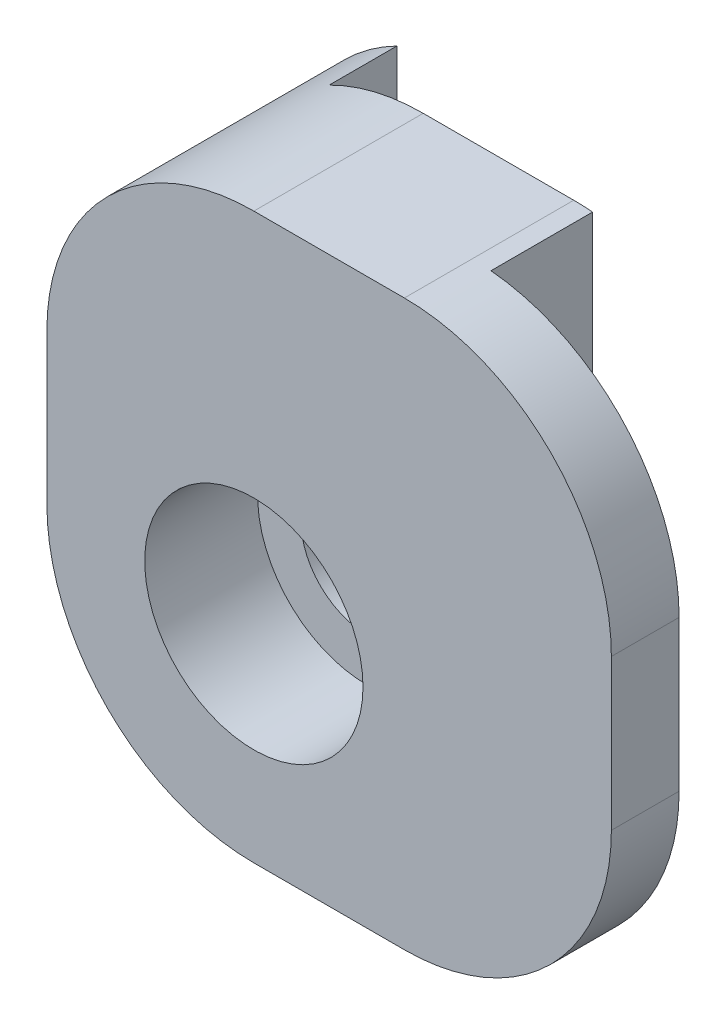
from build123d import *

# Parameters (mm, degrees)
ESBO_O3_W                = 7
ESBO_O3_H                = 12
ESBO_O3_R                = 1.75
RESSALTO_EXTRUS_O2_DEPTH = 2.7
ESBO_O4_W                = 7
ESBO_O4_H                = 12
ESBO_O4_R                = 1.75
RESSALTO_EXTRUS_O3_DEPTH = 2.1
ESBO_O5_W                = 2.1
ESBO_O5_H                = 12
RESSALTO_EXTRUS_O4_DEPTH = 5
RESSALTO_EXTRUS_O5_DEPTH = 3
ESBO_O7_W                = 4.8
ESBO_O7_H                = 15
RESSALTO_EXTRUS_O6_DEPTH = 3
ESBO_O8_R                = 2.9
CORTE_EXTRUS_O1_DEPTH    = 3
FILETE1_R                = 5.5
RESSALTO_EXTRUS_O7_DEPTH = 1.5
CORTE_EXTRUS_O4_DEPTH    = 6.3
CORTE_EXTRUS_O5_DEPTH    = 6.3
RESSALTO_EXTRUS_O8_DEPTH = 0.3
CORTE_EXTRUS_O6_DEPTH    = 0.3
ESBO_O17_R               = 2.9
CORTE_EXTRUS_O7_DEPTH    = 0.3


with BuildPart() as part:
    # Esboço3 → Ressalto-extrusão2 (new body)
    with BuildSketch(Plane.XY):
        with Locations((-3.5, 6)):
            Rectangle(ESBO_O3_W, ESBO_O3_H)
        with Locations((-2.5, 2.5)):
            Circle(ESBO_O3_R, mode=Mode.SUBTRACT)
    extrude(amount=RESSALTO_EXTRUS_O2_DEPTH)

    # Esboço4 → Ressalto-extrusão3 (add)
    with BuildSketch(Plane.XY.offset(2.7)):
        with Locations((-3.5, 6)):
            Rectangle(ESBO_O4_W, ESBO_O4_H)
        with Locations((-2.5, 2.5)):
            Circle(ESBO_O4_R, mode=Mode.SUBTRACT)
    extrude(amount=RESSALTO_EXTRUS_O3_DEPTH)

    # Esboço5 → Ressalto-extrusão4 (add)
    with BuildSketch(Plane.ZY.offset(7)):
        with Locations((3.75, 6)):
            Rectangle(ESBO_O5_W, ESBO_O5_H)
    extrude(amount=RESSALTO_EXTRUS_O4_DEPTH)

    # Esboço6 → Ressalto-extrusão5 (add)
    with BuildSketch(Plane.XZ):
        Polygon((-7, 0), (0, 0), (0, 4.8), (-12, 4.8), (-12, 2.7), (-7, 2.7), align=None)
    extrude(amount=RESSALTO_EXTRUS_O5_DEPTH)

    # Esboço7 → Ressalto-extrusão6 (add)
    with BuildSketch(Plane(origin=(0, 0, 0), x_dir=(0, 0, -1), z_dir=(1, 0, 0))):
        with Locations((-2.4, 4.5)):
            Rectangle(ESBO_O7_W, ESBO_O7_H)
    extrude(amount=RESSALTO_EXTRUS_O6_DEPTH)

    # Esboço8 → Corte-extrusão1 (cut)
    with BuildSketch(Plane.XY.offset(4.8)):
        with Locations((-2.5, 2.5)):
            Circle(ESBO_O8_R)
    extrude(amount=-CORTE_EXTRUS_O1_DEPTH, mode=Mode.SUBTRACT)

    # Filete1
    filete1_edges = [part.edges().sort_by_distance(p)[0] for p in [
        (3, -3, 2.4),
    ]]
    fillet(filete1_edges, radius=FILETE1_R)

    # Esboço10 → Ressalto-extrusão7 (add)
    with BuildSketch(Plane(origin=(0, 0, 0), x_dir=(-1, 0, 0), z_dir=(0, 0, -1))):
        with BuildLine():
            Line((7, 0), (0, 0))
            Line((0, 0), (0, 12))
            Line((0, 12), (-3, 12))
            Line((-3, 12), (-3, 2.5))
            ThreePointArc((-3, 2.5), (-1.389087297, -1.389087297), (2.5, -3))
            Line((2.5, -3), (7, -3))
            Line((7, -3), (7, 0))
        make_face()
    extrude(amount=RESSALTO_EXTRUS_O7_DEPTH)

    # Esboço14 → Corte-extrusão4 (cut)
    with BuildSketch(Plane.XY.offset(4.8)):
        with BuildLine():
            Line((-12, 12), (-12, 6.5))
            ThreePointArc((-12, 6.5), (-10.389087297, 10.389087297), (-6.5, 12))
            Line((-6.5, 12), (-12, 12))
        make_face()
        with BuildLine():
            ThreePointArc((-2.5, 12), (1.389087297, 10.389087297), (3, 6.5))
            Line((3, 6.5), (3, 12))
            Line((3, 12), (-2.5, 12))
        make_face()
    extrude(amount=-CORTE_EXTRUS_O4_DEPTH, mode=Mode.SUBTRACT)

    # Esboço13 → Corte-extrusão5 (cut)
    with BuildSketch(Plane.XY.offset(4.8)):
        with BuildLine():
            Line((-12, -3), (-6.5, -3))
            ThreePointArc((-6.5, -3), (-10.389087297, -1.389087297), (-12, 2.5))
            Line((-12, 2.5), (-12, -3))
        make_face()
    extrude(amount=-CORTE_EXTRUS_O5_DEPTH, mode=Mode.SUBTRACT)

    # Esboço15 → Ressalto-extrusão8 (add)
    with BuildSketch(Plane(origin=(0, 0, -1.5), x_dir=(-1, 0, 0), z_dir=(0, 0, -1))):
        with BuildLine():
            Line((2.5, -3), (6.5, -3))
            ThreePointArc((6.5, -3), (6.750259203, -2.994303444), (7, -2.977225575))
            Line((7, -2.977225575), (7, 0))
            Line((7, 0), (0, 0))
            Line((0, 0), (0, 11.398979486))
            ThreePointArc((0, 11.398979486), (-2.19041576, 9.372281323), (-3, 6.5))
            Line((-3, 6.5), (-3, 2.5))
            ThreePointArc((-3, 2.5), (-1.389087297, -1.389087297), (2.5, -3))
        make_face()
    extrude(amount=RESSALTO_EXTRUS_O8_DEPTH)


with BuildPart() as body_2:
    # Espelhar3: mirrored copy
    add(part.part.mirror(Plane(origin=(4, 0, 0), x_dir=(0, 0, 1), z_dir=(1, 0, 0))))

    # Esboço16 → Corte-extrusão6 (cut)
    with BuildSketch(Plane.XY.offset(4.8)):
        with BuildLine():
            Line((20, 2.5), (20, 6.5))
            ThreePointArc((20, 6.5), (18.389087297, 10.389087297), (14.5, 12))
            Line((14.5, 12), (10.5, 12))
            ThreePointArc((10.5, 12), (6.610912703, 10.389087297), (5, 6.5))
            Line((5, 6.5), (5, 2.5))
            ThreePointArc((5, 2.5), (6.610912703, -1.389087297), (10.5, -3))
            Line((10.5, -3), (14.5, -3))
            ThreePointArc((14.5, -3), (18.389087297, -1.389087297), (20, 2.5))
        make_face()
    extrude(amount=-CORTE_EXTRUS_O6_DEPTH, mode=Mode.SUBTRACT)

    # Esboço17 → Corte-extrusão7 (cut)
    with BuildSketch(Plane.XY.offset(1.8)):
        with Locations((10.5, 2.5)):
            Circle(ESBO_O17_R)
    extrude(amount=-CORTE_EXTRUS_O7_DEPTH, mode=Mode.SUBTRACT)


solid = body_2.part
